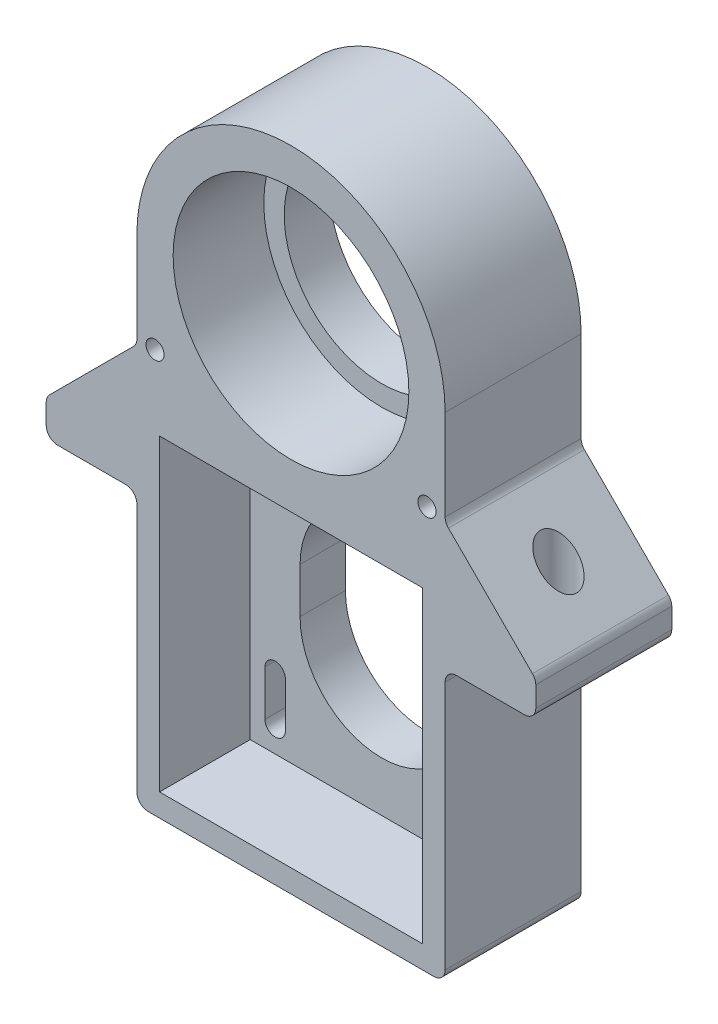
from build123d import *

# Parameters (mm, degrees)
ESQUISSE1_R             = 2
ESQUISSE1_W             = 58
ESQUISSE1_H             = 68
ESQUISSE1_R_2           = 26
BOSS_EXTRU_1_DEPTH      = 20
ESQUISSE1_4_R           = 2
ESQUISSE1_4_R_2         = 21.5
BOSS_EXTRU_2_DEPTH      = 10
ESQUISSE2_R             = 4
ENL_V_MAT_EXTRU_2_DEPTH = 84
CONG_1_R                = 2.5


with BuildPart() as part:
    # Esquisse1 → Boss.-Extru.1 (new body)
    with BuildSketch(Plane.XY):
        with BuildLine():
            Line((34, -109), (34, -49))
            Line((34, -49), (54, -49))
            Line((54, -49), (54, -41))
            Line((54, -41), (34, -21))
            Line((34, -21), (34, 0))
            ThreePointArc((34, 0), (0, 34), (-34, 0))
            Line((-34, 0), (-34, -21))
            Line((-34, -21), (-54, -41))
            Line((-54, -41), (-54, -49))
            Line((-54, -49), (-34, -49))
            Line((-34, -49), (-34, -109))
            Line((-34, -109), (34, -109))
        make_face()
        with Locations((-30, -20)):
            Circle(ESQUISSE1_R, mode=Mode.SUBTRACT)
        with Locations((0, -70)):
            Rectangle(ESQUISSE1_W, ESQUISSE1_H, mode=Mode.SUBTRACT)
        Circle(ESQUISSE1_R_2, mode=Mode.SUBTRACT)
        with Locations((30, -20)):
            Circle(ESQUISSE1_R, mode=Mode.SUBTRACT)
    extrude(amount=BOSS_EXTRU_1_DEPTH)

    # Esquisse1_4 → Boss.-Extru.2 (add)
    with BuildSketch(Plane.XY):
        with BuildLine():
            Line((34, -109), (34, -49))
            Line((34, -49), (54, -49))
            Line((54, -49), (54, -41))
            Line((54, -41), (34, -21))
            Line((34, -21), (34, 0))
            ThreePointArc((34, 0), (0, 34), (-34, 0))
            Line((-34, 0), (-34, -21))
            Line((-34, -21), (-54, -41))
            Line((-54, -41), (-54, -49))
            Line((-54, -49), (-34, -49))
            Line((-34, -49), (-34, -109))
            Line((-34, -109), (34, -109))
        make_face()
        with Locations((-30, -20)):
            Circle(ESQUISSE1_4_R, mode=Mode.SUBTRACT)
        with BuildLine():
            Line((34, -31), (34, -41))
            Line((34, -41), (25.693741097, -41))
            ThreePointArc((25.693741097, -41), (25.735891038, -41.248422445), (25.75, -41.5))
            Line((25.75, -41.5), (25.75, -51.5))
            ThreePointArc((25.75, -51.5), (23.5, -53.75), (21.25, -51.5))
            Line((21.25, -51.5), (21.25, -41.5))
            ThreePointArc((21.25, -41.5), (21.264108962, -41.248422445), (21.306258903, -41))
            Line((21.306258903, -41), (-21.306258903, -41))
            ThreePointArc((-21.306258903, -41), (-23.5, -39.25), (-25.693741097, -41))
            Line((-25.693741097, -41), (-34, -41))
            Line((-34, -41), (-34, -31))
            Line((-34, -31), (34, -31))
        make_face(mode=Mode.SUBTRACT)
        with BuildLine():
            ThreePointArc((18, -75), (0, -93), (-18, -75))
            Line((-18, -75), (-18, -65))
            ThreePointArc((-18, -65), (0, -47), (18, -65))
            Line((18, -65), (18, -75))
        make_face(mode=Mode.SUBTRACT)
        with BuildLine():
            Line((25.75, -88.5), (25.75, -98.5))
            ThreePointArc((25.75, -98.5), (23.5, -100.75), (21.25, -98.5))
            Line((21.25, -98.5), (21.25, -88.5))
            ThreePointArc((21.25, -88.5), (23.5, -86.25), (25.75, -88.5))
        make_face(mode=Mode.SUBTRACT)
        with BuildLine():
            ThreePointArc((-21.25, -98.5), (-23.5, -100.75), (-25.75, -98.5))
            Line((-25.75, -98.5), (-25.75, -88.5))
            ThreePointArc((-25.75, -88.5), (-23.5, -86.25), (-21.25, -88.5))
            Line((-21.25, -88.5), (-21.25, -98.5))
        make_face(mode=Mode.SUBTRACT)
        Circle(ESQUISSE1_4_R_2, mode=Mode.SUBTRACT)
        with Locations((30, -20)):
            Circle(ESQUISSE1_4_R, mode=Mode.SUBTRACT)
    extrude(amount=-BOSS_EXTRU_2_DEPTH)

    # Esquisse2 → Enlèv. mat.-Extru.2 (cut, through all)
    with BuildSketch(Plane.XZ.offset(49)):
        with Locations((44, 5)):
            Circle(ESQUISSE2_R)
        with Locations((-44, 5)):
            Circle(ESQUISSE2_R)
    extrude(amount=-ENL_V_MAT_EXTRU_2_DEPTH, mode=Mode.SUBTRACT)

    # Congé1
    cong_1_edges = [part.edges().sort_by_distance(p)[0] for p in [
        (34, -21, 5),
        (54, -41, 5),
        (54, -49, 5),
        (34, -49, 5),
        (34, -109, 5),
        (-34, -109, 5),
        (-34, -49, 5),
        (-54, -49, 5),
        (-54, -41, 5),
        (-34, -21, 5),
    ]]
    fillet(cong_1_edges, radius=CONG_1_R)


solid = part.part
